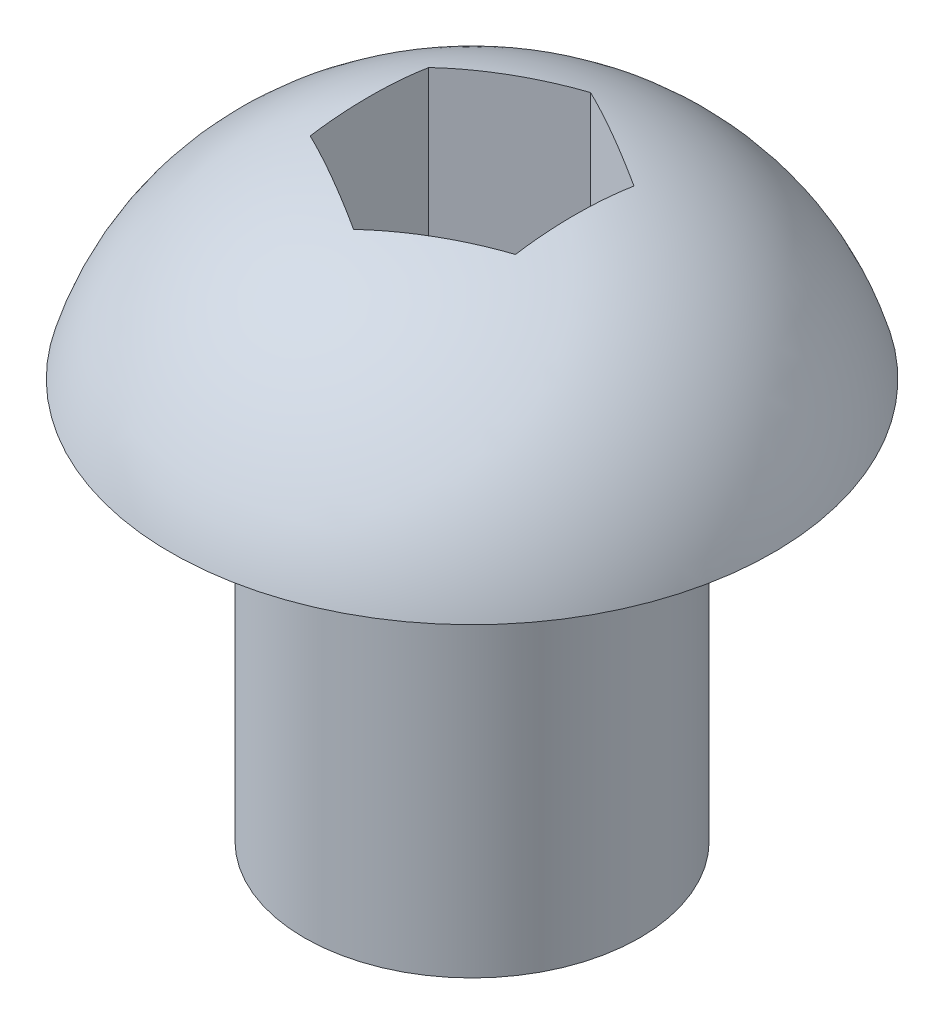
from build123d import *

# Parameters (mm, degrees)
CUT_EXTRUDE1_DEPTH = 2.54


with BuildPart() as part:
    # Sketch1 → Revolve1 (revolve)
    with BuildSketch(Plane.XY):
        with BuildLine():
            Line((0, 0), (0, 8.7122))
            Line((0, 8.7122), (0.490735938, 8.7122))
            ThreePointArc((0.490735938, 8.7122), (2.913197513, 7.899826069), (4.3561, 5.7912))
            Line((4.3561, 5.7912), (2.4257, 5.7912))
            Line((2.4257, 5.7912), (2.4257, 0))
            Line((2.4257, 0), (0, 0))
        make_face()
    revolve(axis=Axis((0, 0, 0), (0, 1, 0)))

    # Sketch2 → Cut-Extrude1 (cut)
    with BuildSketch(Plane(origin=(0, 8.7122, 0), x_dir=(1, 0, 0), z_dir=(0, 1, 0))):
        Polygon((0, -1.7145), (1.484800555, -0.85725), (1.484800555, 0.85725), (0, 1.7145), (-1.484800555, 0.85725), (-1.484800555, -0.85725), align=None)
    extrude(amount=-CUT_EXTRUDE1_DEPTH, mode=Mode.SUBTRACT)


solid = part.part
